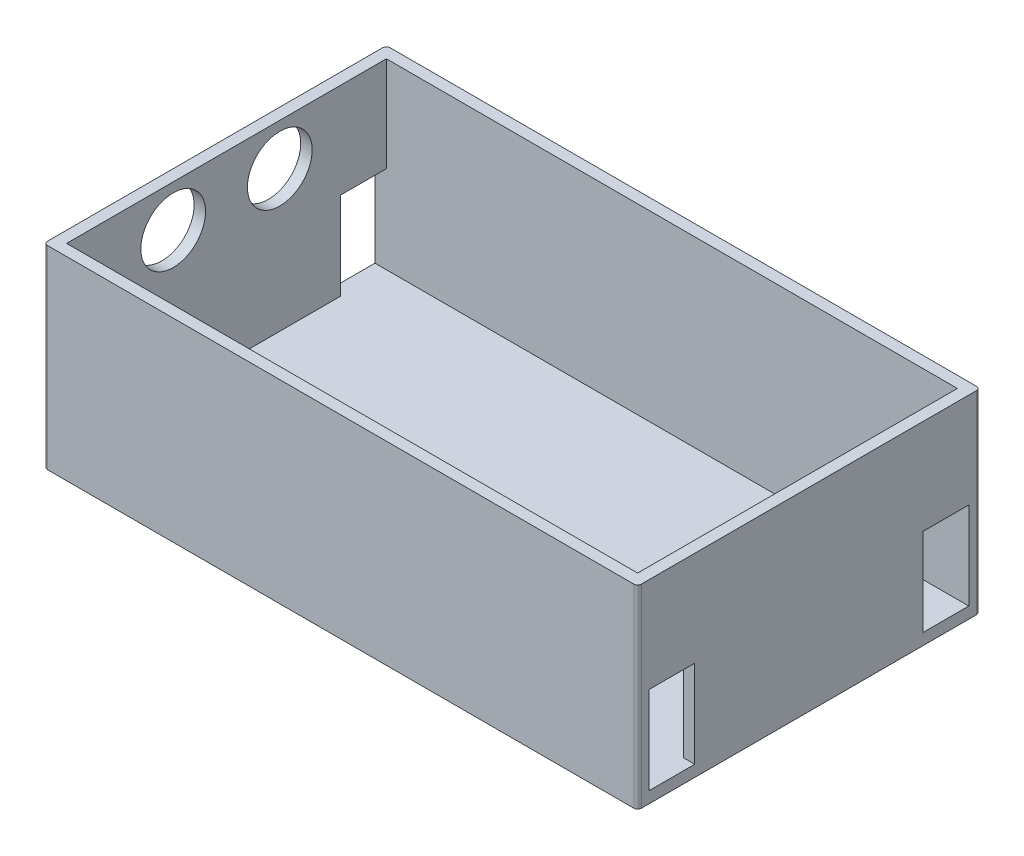
from build123d import *

# Parameters (mm, degrees)
SKETCH1_W           = 156
SKETCH1_H           = 90
BOSS_EXTRUDE1_DEPTH = 3
SKETCH2_W           = 156
SKETCH2_H           = 90
SKETCH2_W_2         = 150
SKETCH2_H_2         = 84
BOSS_EXTRUDE2_DEPTH = 48
FILLET1_R           = 1
SKETCH3_W           = 12
SKETCH3_H           = 23
CUT_EXTRUDE2_DEPTH  = 157
SKETCH4_R           = 8.5
CUT_EXTRUDE3_DEPTH  = 10


with BuildPart() as part:
    # Sketch1 → Boss-Extrude1 (new body)
    with BuildSketch(Plane(origin=(0, 0, 0), x_dir=(1, 0, 0), z_dir=(0, 1, 0))):
        with Locations((78, 45)):
            Rectangle(SKETCH1_W, SKETCH1_H)
    extrude(amount=BOSS_EXTRUDE1_DEPTH)

    # Sketch2 → Boss-Extrude2 (add)
    with BuildSketch(Plane(origin=(0, 3, 0), x_dir=(1, 0, 0), z_dir=(0, 1, 0))):
        with Locations((78, 45)):
            Rectangle(SKETCH2_W, SKETCH2_H)
        with Locations((78, 45)):
            Rectangle(SKETCH2_W_2, SKETCH2_H_2, mode=Mode.SUBTRACT)
    extrude(amount=BOSS_EXTRUDE2_DEPTH)

    # Fillet1
    fillet1_edges = [part.edges().sort_by_distance(p)[0] for p in [
        (0, 25.5, -90),
        (156, 25.5, -90),
        (156, 25.5, 0),
        (0, 25.5, 0),
    ]]
    fillet(fillet1_edges, radius=FILLET1_R)

    # Sketch3 → Cut-Extrude2 (cut, through all)
    with BuildSketch(Plane(origin=(156, 0, 0), x_dir=(0, 0, -1), z_dir=(1, 0, 0))):
        with Locations((9, 14.5)):
            Rectangle(SKETCH3_W, SKETCH3_H)
        with Locations((81, 14.5)):
            Rectangle(SKETCH3_W, SKETCH3_H)
    extrude(amount=-CUT_EXTRUDE2_DEPTH, mode=Mode.SUBTRACT)

    # Sketch4 → Cut-Extrude3 (cut)
    with BuildSketch(Plane.ZY):
        with Locations((-59, 40)):
            Circle(SKETCH4_R)
        with Locations((-31, 40)):
            Circle(SKETCH4_R)
    extrude(amount=-CUT_EXTRUDE3_DEPTH, mode=Mode.SUBTRACT)


solid = part.part
